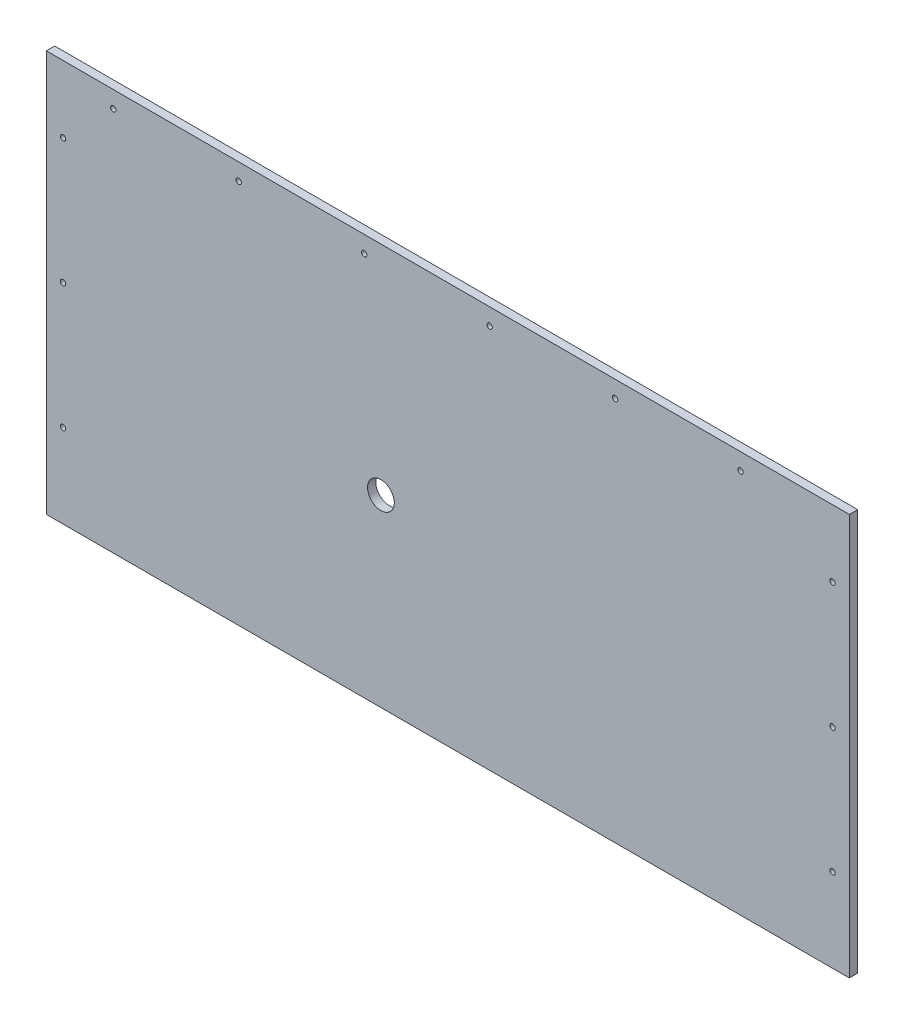
from build123d import *

# Parameters (mm, degrees)
SKETCH1_W           = 609.6
SKETCH1_H           = 304.8
BOSS_EXTRUDE1_DEPTH = 6.35
SKETCH2_R           = 2.032
CUT_EXTRUDE4_DEPTH  = 7.35
SKETCH4_R           = 2.032
CUT_EXTRUDE7_DEPTH  = 7.35
SKETCH5_R           = 10.16
CUT_EXTRUDE8_DEPTH  = 7.35


with BuildPart() as part:
    # Sketch1 → Boss-Extrude1 (new body)
    with BuildSketch(Plane.XY):
        with Locations((304.8, 152.4)):
            Rectangle(SKETCH1_W, SKETCH1_H)
    extrude(amount=BOSS_EXTRUDE1_DEPTH)

    # Sketch2 → Cut-Extrude4 (cut, through all)
    with BuildSketch(Plane.XY.offset(6.35)):
        with Locations((12.7, 254)):
            Circle(SKETCH2_R)
        with Locations((12.7, 158.75)):
            Circle(SKETCH2_R)
        with Locations((12.7, 63.5)):
            Circle(SKETCH2_R)
        with Locations((596.9, 63.5)):
            Circle(SKETCH2_R)
        with Locations((596.9, 158.75)):
            Circle(SKETCH2_R)
        with Locations((596.9, 254)):
            Circle(SKETCH2_R)
    extrude(amount=-CUT_EXTRUDE4_DEPTH, mode=Mode.SUBTRACT)

    # Sketch4 → Cut-Extrude7 (cut, through all)
    with BuildSketch(Plane.XY.offset(6.35)):
        with Locations((50.8, 292.1)):
            Circle(SKETCH4_R)
        with Locations((146.05, 292.1)):
            Circle(SKETCH4_R)
        with Locations((241.3, 292.1)):
            Circle(SKETCH4_R)
        with Locations((336.55, 292.1)):
            Circle(SKETCH4_R)
        with Locations((431.8, 292.1)):
            Circle(SKETCH4_R)
        with Locations((527.05, 292.1)):
            Circle(SKETCH4_R)
    extrude(amount=-CUT_EXTRUDE7_DEPTH, mode=Mode.SUBTRACT)

    # Sketch5 → Cut-Extrude8 (cut, through all)
    with BuildSketch(Plane(origin=(0, 0, 0), x_dir=(-1, 0, 0), z_dir=(0, 0, -1))):
        with Locations((-254, 139.7)):
            Circle(SKETCH5_R)
    extrude(amount=-CUT_EXTRUDE8_DEPTH, mode=Mode.SUBTRACT)


solid = part.part
